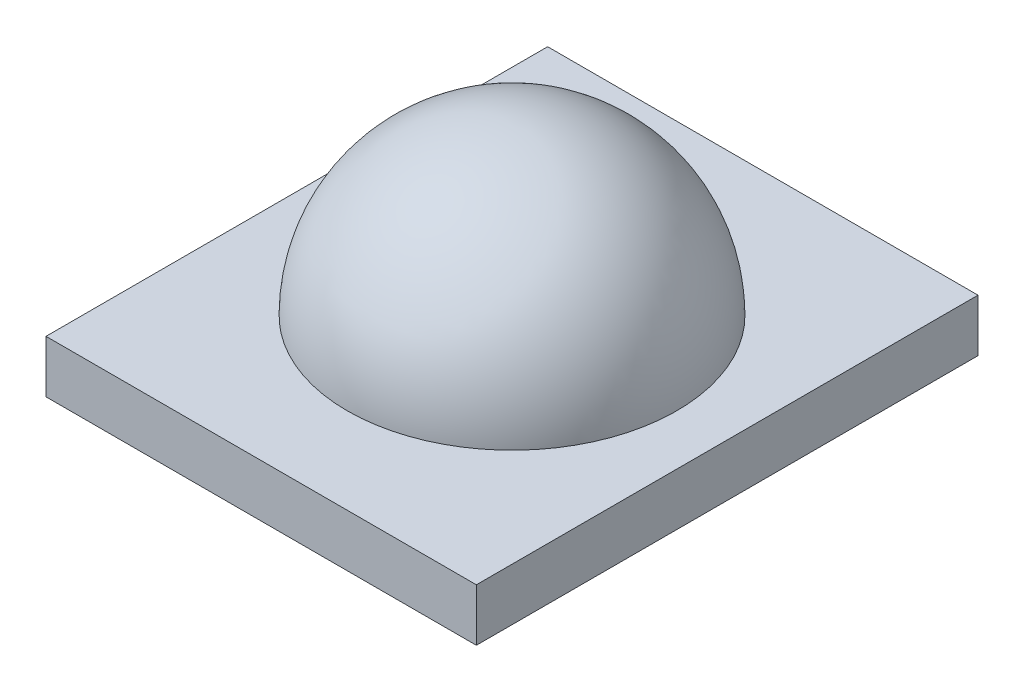
from build123d import *

# Parameters (mm, degrees)
SKETCH1_W           = 28.74
SKETCH1_H           = 33.5
BOSS_EXTRUDE1_DEPTH = 3.5


with BuildPart() as part:
    # Sketch1 → Boss-Extrude1 (new body)
    with BuildSketch(Plane(origin=(0, 0, 0), x_dir=(1, 0, 0), z_dir=(0, 1, 0))):
        Rectangle(SKETCH1_W, SKETCH1_H)
    extrude(amount=BOSS_EXTRUDE1_DEPTH)

    # Sketch4 → Revolve1 (revolve)
    with BuildSketch(Plane(origin=(0, 0, 0), x_dir=(0, 0, -1), z_dir=(1, 0, 0))):
        with BuildLine():
            Line((0, 0), (-11, 0))
            Line((-11, 0), (-11, 3.4))
            ThreePointArc((-11, 3.4), (-7.813771351, 11.243059943), (0, 14.500454536))
            Line((0, 14.500454536), (0, 0))
        make_face()
    revolve(axis=Axis((0, 14.500454536, 0), (0, -1, 0)))


solid = part.part
